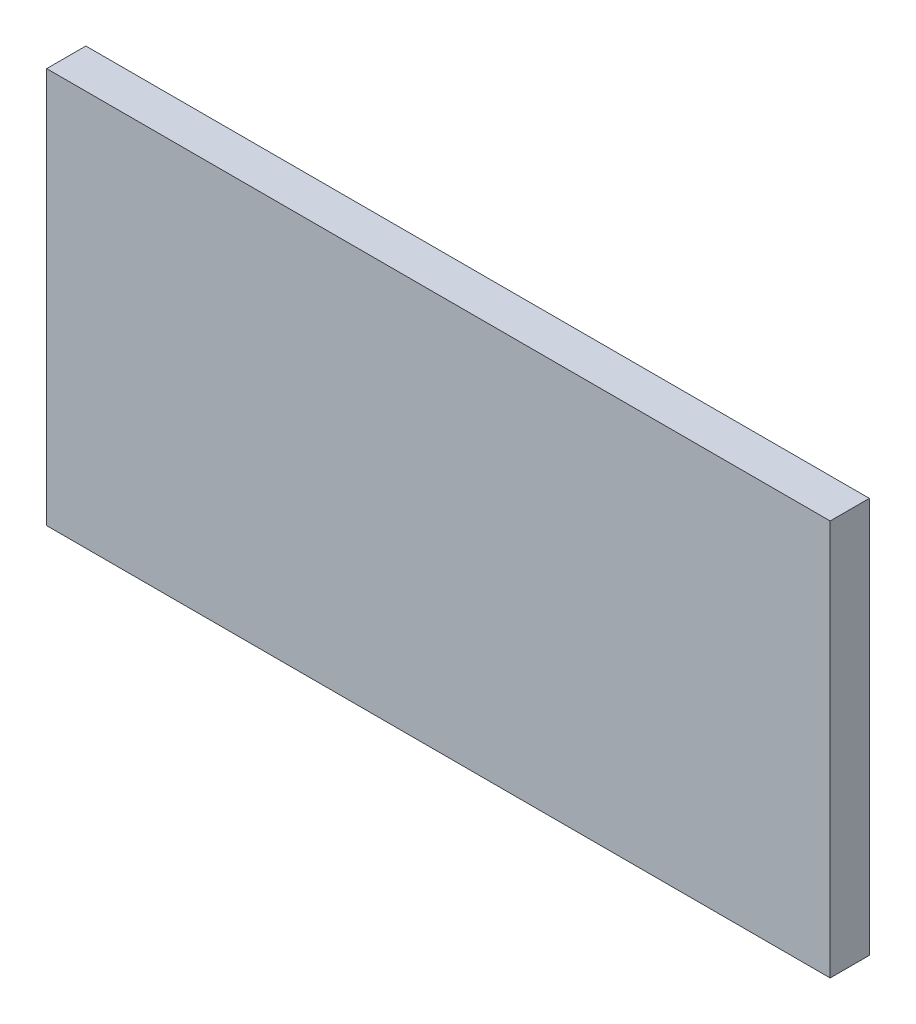
from build123d import *

# Parameters (mm, degrees)
SKETCH1_W           = 12
SKETCH1_H           = 121.24
BOSS_EXTRUDE1_DEPTH = 240


with BuildPart() as part:
    # Sketch1 → Boss-Extrude1 (new body)
    with BuildSketch(Plane(origin=(0, 0, 0), x_dir=(0, 0, -1), z_dir=(1, 0, 0))):
        with Locations((6, -60.62)):
            Rectangle(SKETCH1_W, SKETCH1_H)
    extrude(amount=-BOSS_EXTRUDE1_DEPTH)


solid = part.part
